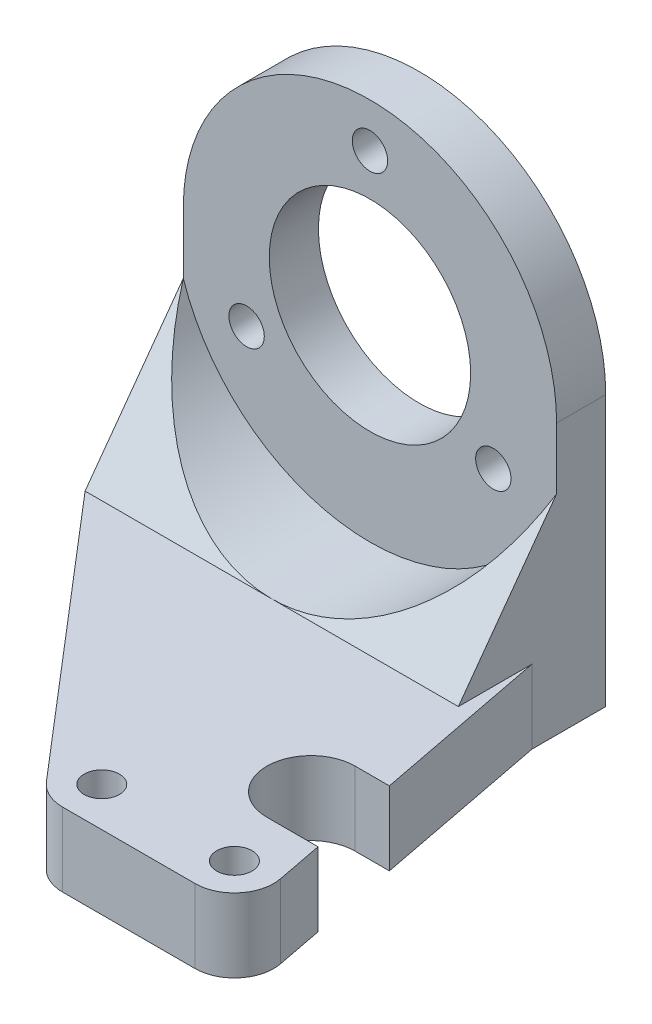
from build123d import *

# Parameters (mm, degrees)
SKETCH1_R            = 10.25
BOSS_EXTRUDE1_DEPTH  = 5
M3_CLEARANCE_HOLE1_D = 3.6
CIRPATTERN1_COUNT    = 3
BOSS_EXTRUDE2_DEPTH  = 15
BOSS_EXTRUDE3_DEPTH  = 7.5
M3_CLEARANCE_HOLE2_D = 3.6
CUT_EXTRUDE1_DEPTH   = 45.2
CUT_EXTRUDE2_DEPTH   = 47.5


with BuildPart() as part:
    # Sketch1 → Boss-Extrude1 (new body)
    with BuildSketch(Plane.XY):
        with BuildLine():
            Line((19, -27.5), (19, 0))
            ThreePointArc((19, 0), (0, 19), (-19, 0))
            Line((-19, 0), (-19, -27.5))
            Line((-19, -27.5), (19, -27.5))
        make_face()
        Circle(SKETCH1_R, mode=Mode.SUBTRACT)
    extrude(amount=BOSS_EXTRUDE1_DEPTH)

    # M3 Clearance Hole1 (through all)
    with Locations(Plane.XY.offset(5)):
        with Locations((0, 14.5)):
            m3_clearance_hole1 = Hole(M3_CLEARANCE_HOLE1_D / 2)

    # CirPattern1: M3 Clearance Hole1 ×3 about axis
    cirpattern1_axis = Axis((0, 0, 0), (0, 0, 1))
    for i in range(1, CIRPATTERN1_COUNT):
        add(m3_clearance_hole1.rotate(cirpattern1_axis, i * 360 / CIRPATTERN1_COUNT), mode=Mode.SUBTRACT)

    # Sketch6 → Boss-Extrude2 (add)
    with BuildSketch(Plane.XY):
        with BuildLine():
            ThreePointArc((19, -6.244997998), (0, -20), (-19, -6.244997998))
            Line((-19, -6.244997998), (-19, -27.5))
            Line((-19, -27.5), (19, -27.5))
            Line((19, -27.5), (19, -6.244997998))
        make_face()
    extrude(amount=BOSS_EXTRUDE2_DEPTH)

    # Sketch7 → Boss-Extrude3 (add)
    with BuildSketch(Plane.XZ.offset(27.5)):
        with BuildLine():
            Line((19, 7.5), (25.127490345, 39.241831423))
            ThreePointArc((25.127490345, 39.241831423), (24.284856099, 42.546303761), (21.2, 44))
            Line((21.2, 44), (7.7, 44))
            ThreePointArc((7.7, 44), (6.028691054, 43.634105998), (4.663143067, 42.603363204))
            Line((4.663143067, 42.603363204), (-19, 15))
            Line((-19, 15), (19, 15))
            Line((19, 15), (19, 7.5))
        make_face()
    extrude(amount=-BOSS_EXTRUDE3_DEPTH)

    # M3 Clearance Hole2 (through all)
    with Locations(Plane(origin=(0, -27.5, 0), x_dir=(-1, 0, 0), z_dir=(0, -1, 0))):
        with Locations((-21.2, -40), (-7.7, -40)):
            Hole(M3_CLEARANCE_HOLE2_D / 2)

    # Sketch10 → Cut-Extrude1 (cut, through all)
    with BuildSketch(Plane.ZY.offset(19)):
        Polygon((5, -6.244997998), (15, -20), (15, -6.244997998), align=None)
    extrude(amount=-CUT_EXTRUDE1_DEPTH, mode=Mode.SUBTRACT)

    # Sketch11 → Cut-Extrude2 (cut, through all)
    with BuildSketch(Plane.XZ.offset(27.5)):
        with BuildLine():
            Line((19, 34.5), (24.212120155, 34.5))
            Line((24.212120155, 34.5), (22.47474677, 25.5))
            Line((22.47474677, 25.5), (19, 25.5))
            ThreePointArc((19, 25.5), (14.5, 30), (19, 34.5))
        make_face()
    extrude(amount=-CUT_EXTRUDE2_DEPTH, mode=Mode.SUBTRACT)


solid = part.part
